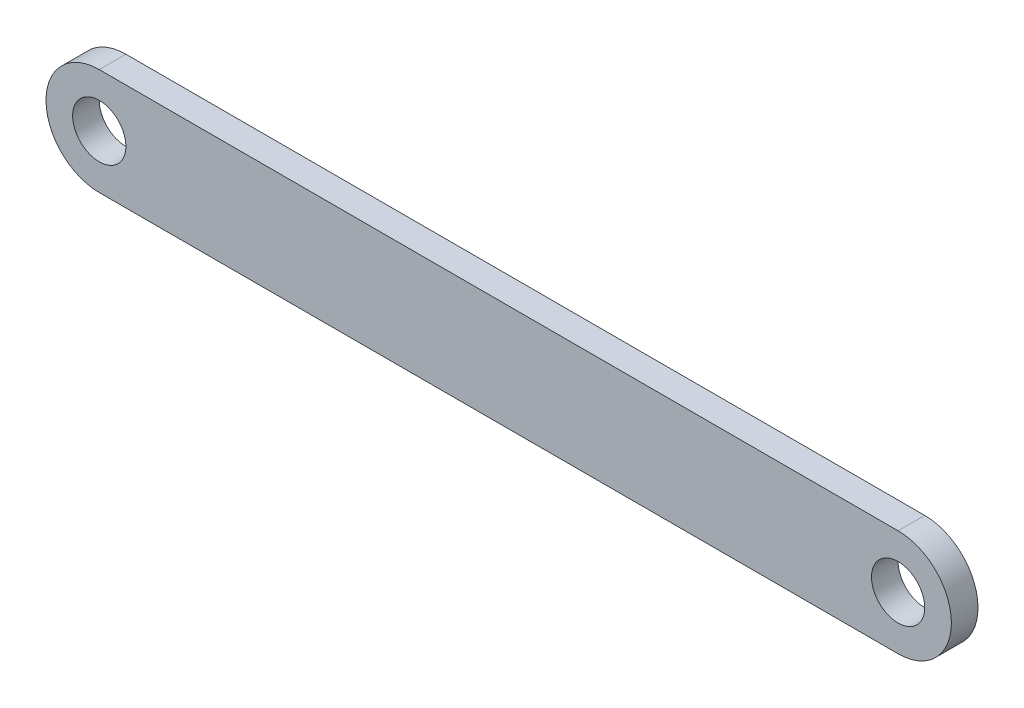
from build123d import *

# Parameters (mm, degrees)
SKETCH1_R           = 2.54
BOSS_EXTRUDE1_DEPTH = 2.54


with BuildPart() as part:
    # Sketch1 → Boss-Extrude1 (new body)
    with BuildSketch(Plane.XY):
        with BuildLine():
            Line((0, -13.881782438), (-76.2, -13.881782438))
            ThreePointArc((-76.2, -13.881782438), (-81.28, -8.801782438), (-76.2, -3.721782438))
            Line((-76.2, -3.721782438), (0, -3.721782438))
            ThreePointArc((0, -3.721782438), (5.08, -8.801782438), (0, -13.881782438))
        make_face()
        with Locations((-76.2, -8.801782438)):
            Circle(SKETCH1_R, mode=Mode.SUBTRACT)
        with Locations((0, -8.801782438)):
            Circle(SKETCH1_R, mode=Mode.SUBTRACT)
    extrude(amount=BOSS_EXTRUDE1_DEPTH)


solid = part.part
